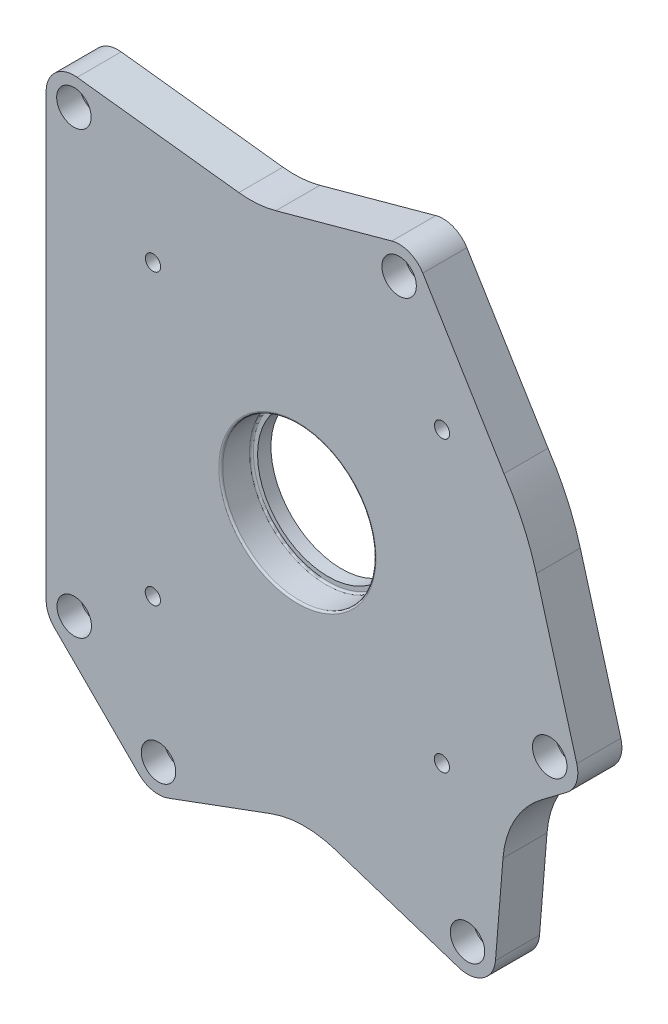
from build123d import *

# Parameters (mm, degrees)
BOSS_EXTRUDE1_DEPTH             = 23
FILLET2_R                       = 50.8
SKETCH2_R                       = 40.05
CUT_EXTRUDE1_DEPTH              = 16
SKETCH5_R                       = 36.83
CUT_EXTRUDE2_DEPTH              = 25.4
FILLET5_R                       = 1
FILLET6_R                       = 1
CBORE_FOR_M10_SHCS7_D           = 10.5
CBORE_FOR_M10_SHCS7_CBORE_D     = 18
CBORE_FOR_M10_SHCS7_CBORE_DEPTH = 12
F_10_0MM_DOWEL_HOLE3_D          = 10
F_10_0MM_DOWEL_HOLE3_DEPTH      = 10
F_10_0MM_DOWEL_HOLE3_TIP        = 3.004303095
TAP_DRILL_FOR_3_8_16_TAP1_D     = 7.9375


with BuildPart() as part:
    # Sketch1 → Boss-Extrude1 (new body)
    with BuildSketch(Plane.XY):
        with BuildLine():
            Line((84.221105008, -163.490124242), (2.699306526, -136.831626991))
            Line((2.699306526, -136.831626991), (-67.458438584, -162.730244564))
            ThreePointArc((-67.458438584, -162.730244564), (-75.680634631, -163.297391653), (-82.910842941, -159.341351783))
            Line((-82.910842941, -159.341351783), (-126.914053579, -115.336397895))
            ThreePointArc((-126.914053579, -115.336397895), (-130.093640928, -110.577690662), (-131.210211433, -104.964461595))
            Line((-131.210211433, -104.964461595), (-131.213297338, 125.035476514))
            ThreePointArc((-131.213297338, 125.035476514), (-126.350161673, 135.869915187), (-115.02264263, 139.436771249))
            Line((-115.02264263, 139.436771249), (-20.796830867, 128.37488637))
            Line((-20.796830867, 128.37488637), (49.24312976, 147.55277548))
            ThreePointArc((49.24312976, 147.55277548), (58.421803723, 147.044752766), (65.450410839, 141.119820294))
            Line((65.450410839, 141.119820294), (107.841002341, 71.642808501))
            ThreePointArc((107.841002341, 71.642808501), (117.701476238, 53.952608996), (124.683759391, 34.941564155))
            Line((124.683759391, 34.941564155), (145.845410308, -40.455794779))
            ThreePointArc((145.845410308, -40.455794779), (145.61886709, -49.11646402), (140.544799405, -56.138739339))
            Line((140.544799405, -56.138739339), (109.149264581, -79.773969292))
            Line((109.149264581, -79.773969292), (103.401152517, -150.732337669))
            ThreePointArc((103.401152517, -150.732337669), (96.90432541, -161.761540655), (84.221105008, -163.490124242))
        make_face()
    extrude(amount=BOSS_EXTRUDE1_DEPTH)

    # Fillet2
    fillet2_edges = [part.edges().sort_by_distance(p)[0] for p in [
        (109.149264581, -79.773969292, 11.5),
        (2.699306526, -136.831626991, 11.5),
        (-20.796830867, 128.37488637, 11.5),
    ]]
    fillet(fillet2_edges, radius=FILLET2_R)

    # Sketch2 → Cut-Extrude1 (cut)
    with BuildSketch(Plane(origin=(0, 0, 23), x_dir=(-1, 0, 0), z_dir=(0, 0, -1))):
        Circle(SKETCH2_R)
    extrude(amount=CUT_EXTRUDE1_DEPTH, mode=Mode.SUBTRACT)

    # Sketch5 → Cut-Extrude2 (cut)
    with BuildSketch(Plane(origin=(0, 0, 23), x_dir=(-1, 0, 0), z_dir=(0, 0, -1))):
        Circle(SKETCH5_R)
    extrude(amount=CUT_EXTRUDE2_DEPTH, mode=Mode.SUBTRACT)

    # Fillet5
    fillet5_edges = [part.edges().sort_by_distance(p)[0] for p in [
        (40.05, 0, 23),
    ]]
    fillet(fillet5_edges, radius=FILLET5_R)

    # Fillet6
    fillet6_edges = [part.edges().sort_by_distance(p)[0] for p in [
        (40.05, 0, 7),
    ]]
    fillet(fillet6_edges, radius=FILLET6_R)

    # CBORE for M10 SHCS7 (through all)
    with Locations(Plane.XY.offset(23)):
        with Locations((-116.713297339, 125.03567106), (-116.541509562, -104.964264785), (-72.538298924, -148.969218673), (53.072470058, 133.567563544), (131.722431635, -44.419667636), (88.780343848, -149.547952394)):
            CounterBoreHole(CBORE_FOR_M10_SHCS7_D / 2, CBORE_FOR_M10_SHCS7_CBORE_D / 2, CBORE_FOR_M10_SHCS7_CBORE_DEPTH)

    # Ø10.0mm Dowel Hole3
    with Locations(Plane(origin=(0, 0, 0), x_dir=(-1, 0, 0), z_dir=(0, 0, -1))):
        with Locations((76.55340813, 103.753913834), (-59.102558089, -114.980445858)):
            Hole(F_10_0MM_DOWEL_HOLE3_D / 2, depth=F_10_0MM_DOWEL_HOLE3_DEPTH)
            with Locations((0, 0, -(F_10_0MM_DOWEL_HOLE3_DEPTH + F_10_0MM_DOWEL_HOLE3_TIP / 2))):  # 118° drill point
                Cone(0, F_10_0MM_DOWEL_HOLE3_D / 2, F_10_0MM_DOWEL_HOLE3_TIP, mode=Mode.SUBTRACT)

    # Tap Drill for 3/8-16 Tap1 (through all)
    with Locations(Plane(origin=(75.504350667, 75.417116381, 23), x_dir=(1, 0, 0), z_dir=(0, 0, 1))):
        with Locations((0, 0), (-150.921467048, 0.087234286), (-151.008701334, -150.834232762), (-0.087234286, -150.921467048)):
            Hole(TAP_DRILL_FOR_3_8_16_TAP1_D / 2)


solid = part.part
